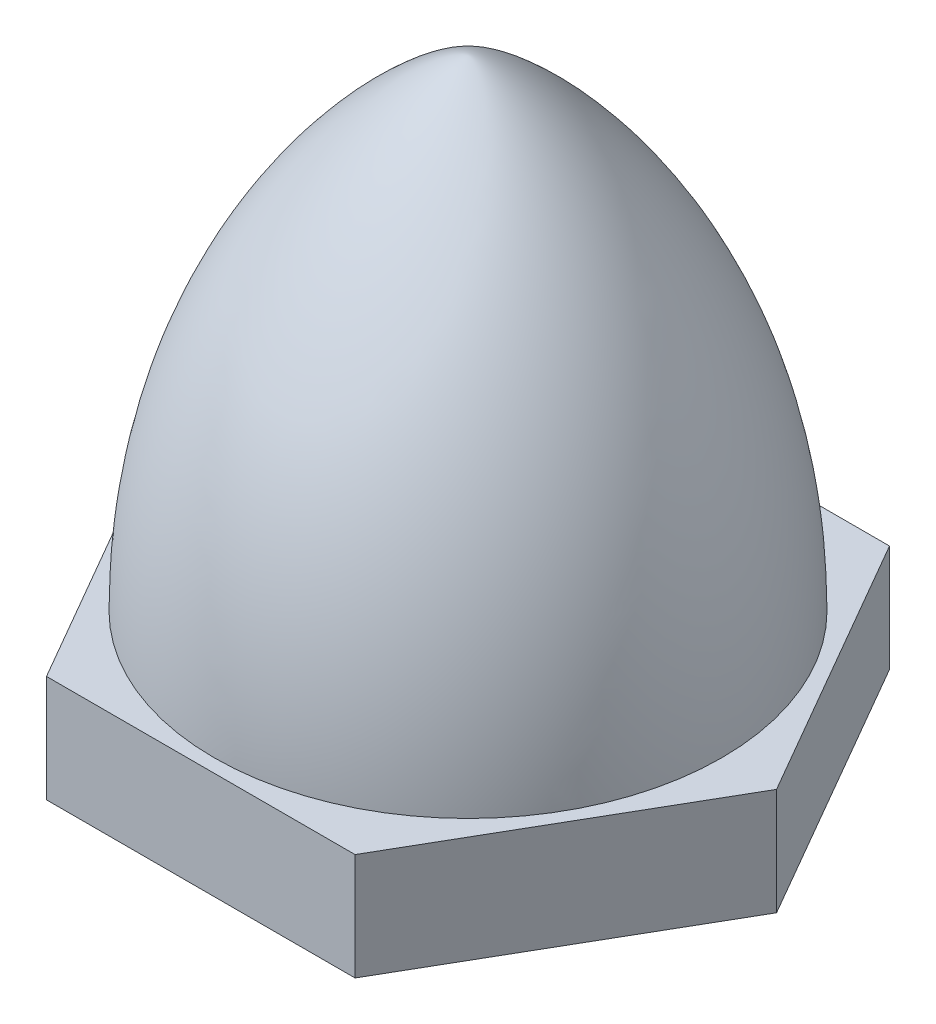
from build123d import *

# Parameters (mm, degrees)
BOSS_EXTRUDE1_DEPTH       = 2
M5X0_8_TAPPED_HOLE1_D     = 4.2
M5X0_8_TAPPED_HOLE1_DEPTH = 5
M5X0_8_TAPPED_HOLE1_TIP   = 1.2618073


with BuildPart() as part:
    # Sketch1 → Boss-Extrude1 (new body)
    with BuildSketch(Plane(origin=(0, 0, 0), x_dir=(1, 0, 0), z_dir=(0, 1, 0))):
        Polygon((2.886751346, 5), (-2.886751346, 5), (-5.773502692, 0), (-2.886751346, -5), (2.886751346, -5), (5.773502692, 0), align=None)
    extrude(amount=BOSS_EXTRUDE1_DEPTH)

    # Sketch2 → Revolve1 (revolve)
    with BuildSketch(Plane.XY):
        with BuildLine():
            Line((4.75, 2), (0, 2))
            Line((0, 2), (0, 11))
            add(Edge.make_bspline(
                [(0, 11), (0.622499022, 11), (4.75, 8.004236855), (4.75, 2)],
                knots=[0, 0, 0, 0, 1, 1, 1, 1], degree=3))
        make_face()
    revolve(axis=Axis((0, 11, 0), (0, -1, 0)))

    # M5x0.8 Tapped Hole1
    with Locations(Plane(origin=(0, 0, 0), x_dir=(-1, 0, 0), z_dir=(0, -1, 0))):
        with Locations((0, 0)):
            Hole(M5X0_8_TAPPED_HOLE1_D / 2, depth=M5X0_8_TAPPED_HOLE1_DEPTH)
            with Locations((0, 0, -(M5X0_8_TAPPED_HOLE1_DEPTH + M5X0_8_TAPPED_HOLE1_TIP / 2))):  # 118° drill point
                Cone(0, M5X0_8_TAPPED_HOLE1_D / 2, M5X0_8_TAPPED_HOLE1_TIP, mode=Mode.SUBTRACT)


solid = part.part
